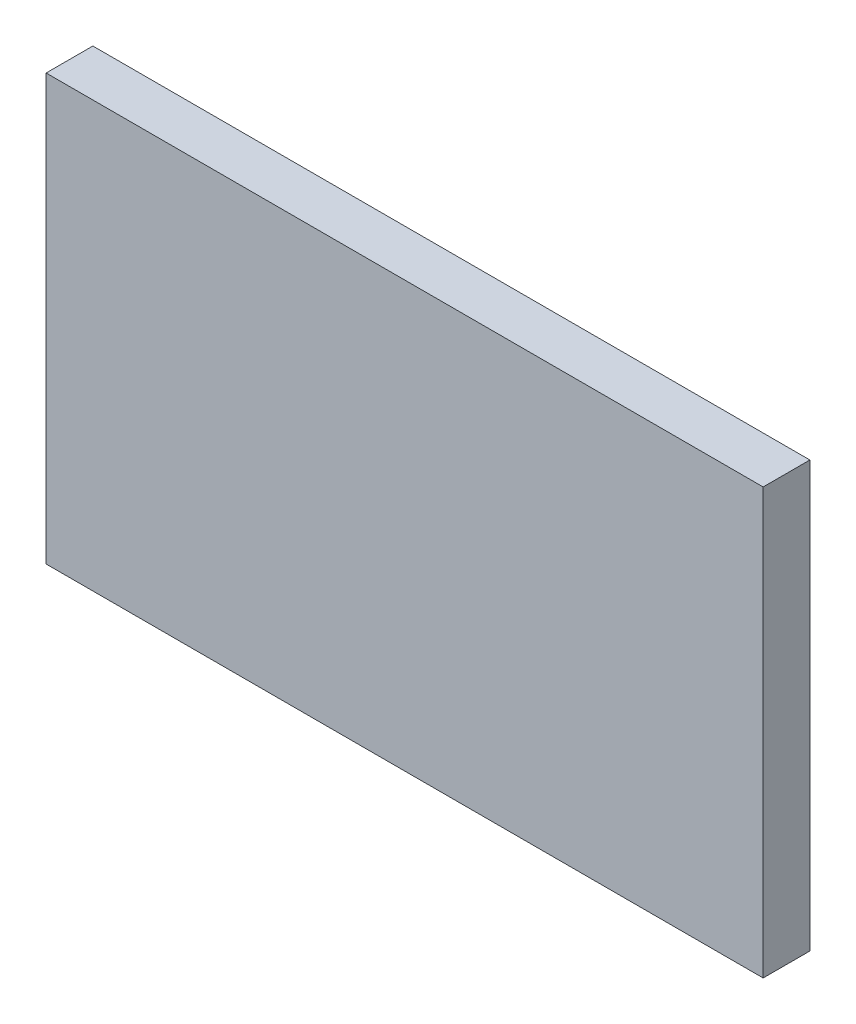
from build123d import *

# Parameters (mm, degrees)
SKETCH2_W           = 76.718161642
SKETCH2_H           = 45.5
BOSS_EXTRUDE1_DEPTH = 5


with BuildPart() as part:
    # Sketch2 → Boss-Extrude1 (new body)
    with BuildSketch(Plane(origin=(0, 0, 0), x_dir=(-1, 0, 0), z_dir=(0, 0, -1))):
        with Locations((184.636580821, -32.25)):
            Rectangle(SKETCH2_W, SKETCH2_H)
    extrude(amount=BOSS_EXTRUDE1_DEPTH)


solid = part.part
